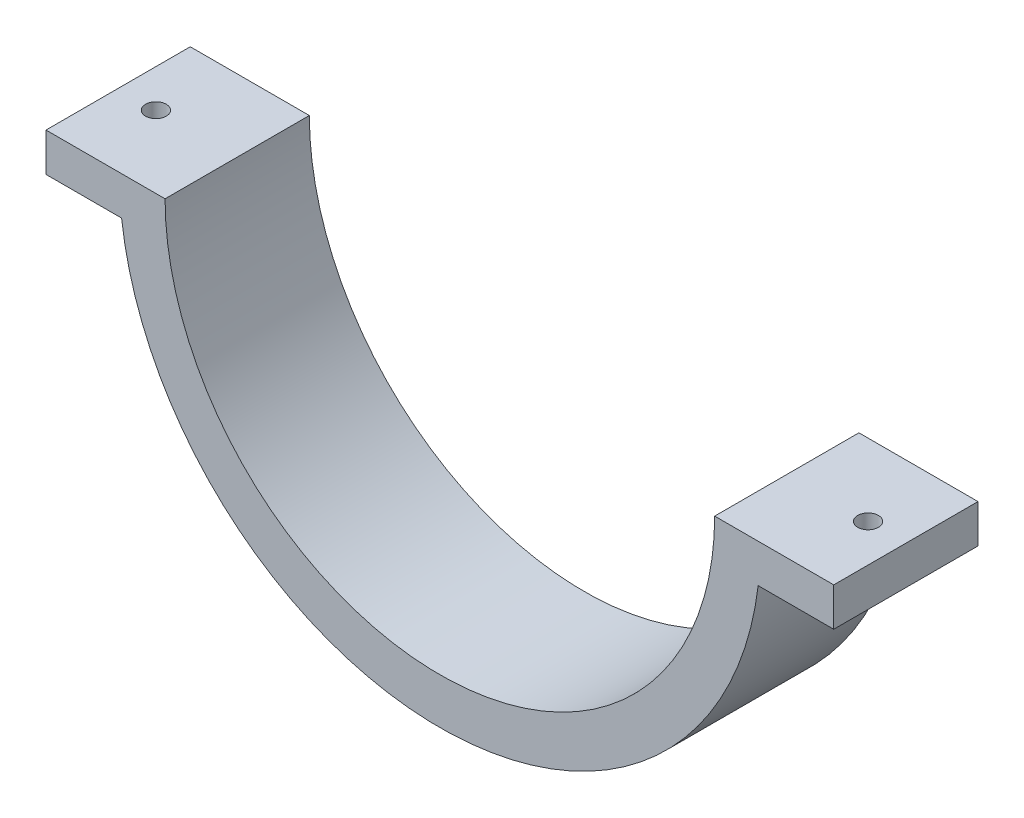
from build123d import *

# Parameters (mm, degrees)
BOSS_EXTRUDE1_DEPTH = 30
SKETCH2_W           = 20
SKETCH2_H           = 8
BOSS_EXTRUDE2_DEPTH = 30
SKETCH3_R           = 2.15265
CUT_EXTRUDE1_DEPTH  = 67.675


with BuildPart() as part:
    # Sketch1 → Boss-Extrude1 (new body)
    with BuildSketch(Plane.XY):
        with BuildLine():
            Line((66.675, 0), (57.15, 0))
            ThreePointArc((57.15, 0), (0, -57.15), (-57.15, 0))
            Line((-57.15, 0), (-66.675, 0))
            ThreePointArc((-66.675, 0), (0, -66.675), (66.675, 0))
        make_face()
    extrude(amount=BOSS_EXTRUDE1_DEPTH)

    # Sketch2 → Boss-Extrude2 (add)
    with BuildSketch(Plane.XY.offset(30)):
        with Locations((71.9125, -4)):
            Rectangle(SKETCH2_W, SKETCH2_H)
        with Locations((-71.9125, -4)):
            Rectangle(SKETCH2_W, SKETCH2_H)
    extrude(amount=-BOSS_EXTRUDE2_DEPTH)

    # Sketch3 → Cut-Extrude1 (cut, through all)
    with BuildSketch(Plane(origin=(0, 0, 0), x_dir=(1, 0, 0), z_dir=(0, 1, 0))):
        with Locations((-74.052910047, -15)):
            Circle(SKETCH3_R)
        with Locations((74.052910047, -15)):
            Circle(SKETCH3_R)
    extrude(amount=-CUT_EXTRUDE1_DEPTH, mode=Mode.SUBTRACT)


solid = part.part
